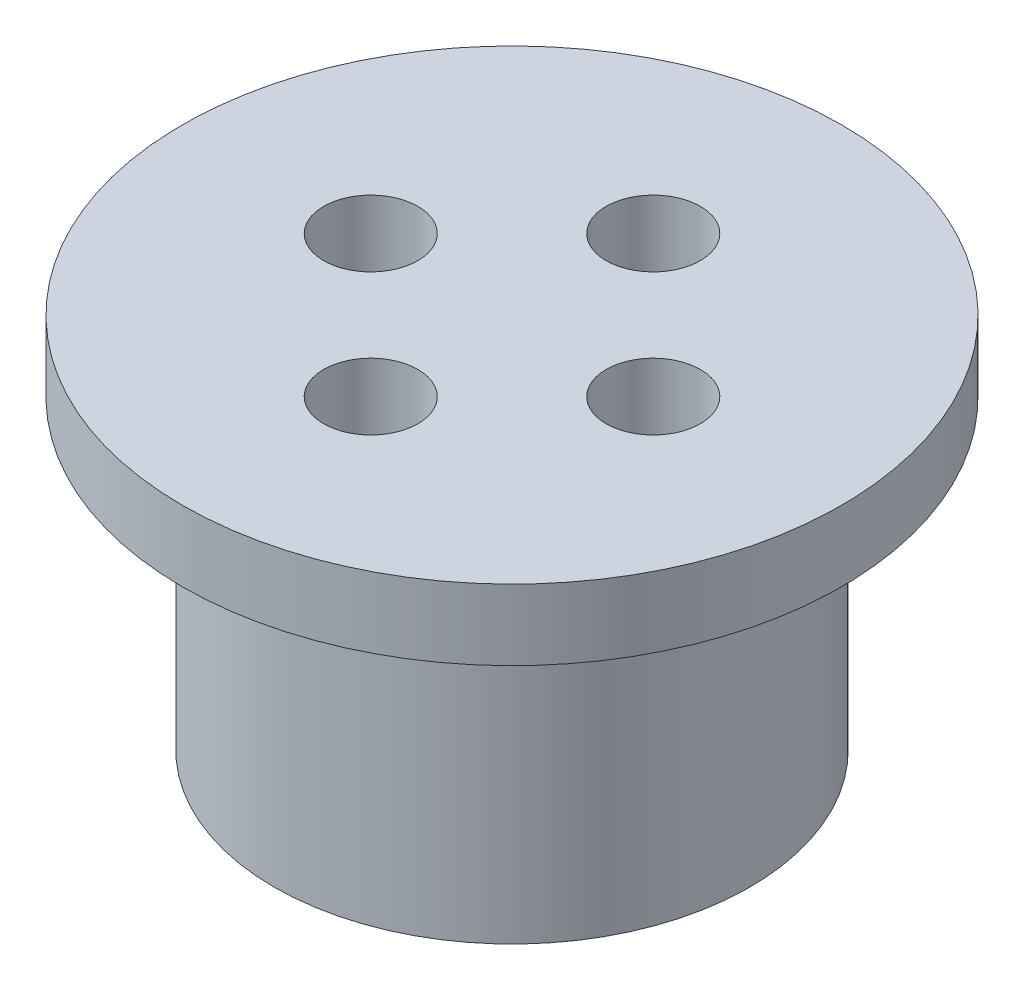
from build123d import *

# Parameters (mm, degrees)
SKETCH1_R           = 10.1
BOSS_EXTRUDE1_DEPTH = 13
SKETCH2_R           = 14
BOSS_EXTRUDE2_DEPTH = 3
SKETCH3_R           = 2
CUT_EXTRUDE1_DEPTH  = 17
CIRPATTERN1_COUNT   = 4


with BuildPart() as part:
    # Sketch1 → Boss-Extrude1 (new body)
    with BuildSketch(Plane(origin=(0, 0, 0), x_dir=(1, 0, 0), z_dir=(0, 1, 0))):
        Circle(SKETCH1_R)
    extrude(amount=BOSS_EXTRUDE1_DEPTH)

    # Sketch2 → Boss-Extrude2 (add)
    with BuildSketch(Plane(origin=(0, 13, 0), x_dir=(1, 0, 0), z_dir=(0, 1, 0))):
        Circle(SKETCH2_R)
    extrude(amount=BOSS_EXTRUDE2_DEPTH)

    # Sketch3 → Cut-Extrude1 (cut, through all)
    with BuildSketch(Plane.XZ):
        with Locations((0, 6)):
            Circle(SKETCH3_R)
    cut_extrude1 = extrude(amount=-CUT_EXTRUDE1_DEPTH, mode=Mode.SUBTRACT)

    # CirPattern1: Cut-Extrude1 ×4 about axis
    cirpattern1_axis = Axis((0, 0, 0), (0, 1, 0))
    for i in range(1, CIRPATTERN1_COUNT):
        add(cut_extrude1.rotate(cirpattern1_axis, i * 360 / CIRPATTERN1_COUNT), mode=Mode.SUBTRACT)


solid = part.part
